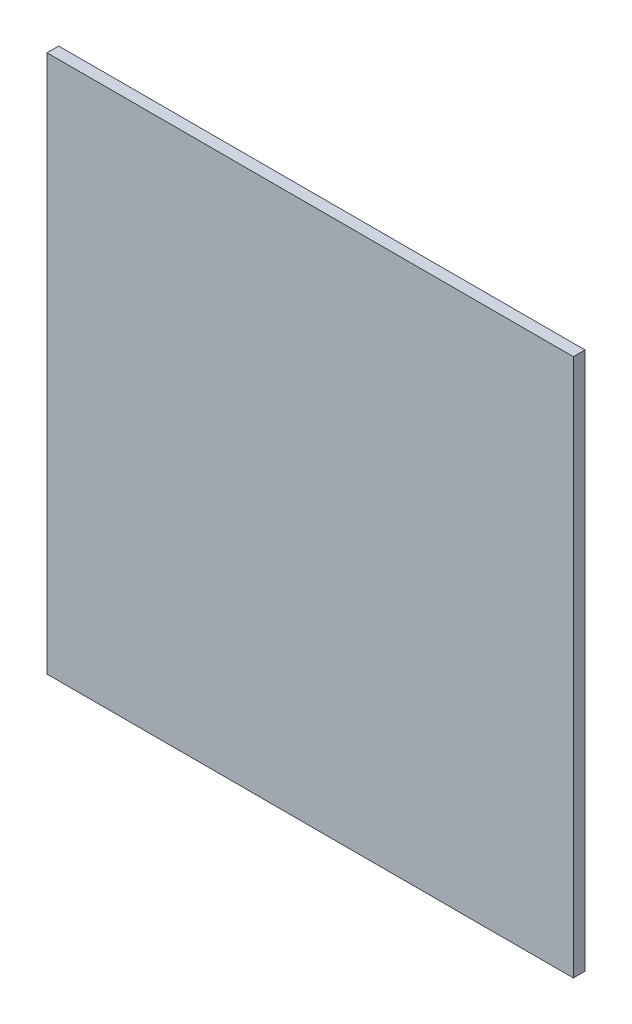
from build123d import *

# Parameters (mm, degrees)
SKETCH1_W           = 142.875
SKETCH1_H           = 146.05
BOSS_EXTRUDE1_DEPTH = 3.175


with BuildPart() as part:
    # Sketch1 → Boss-Extrude1 (new body)
    with BuildSketch(Plane.XY):
        Rectangle(SKETCH1_W, SKETCH1_H)
    extrude(amount=BOSS_EXTRUDE1_DEPTH)


solid = part.part
